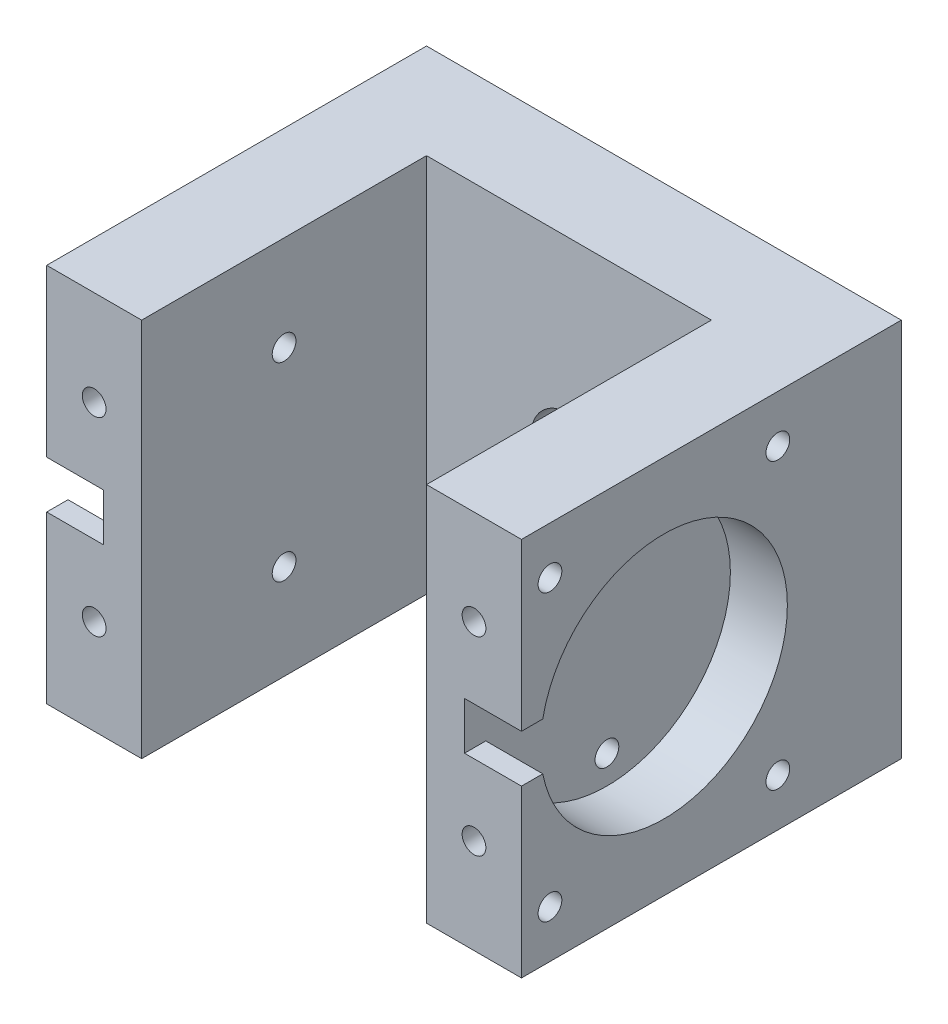
from build123d import *

# Parameters (mm, degrees)
SKETCH1_W                 = 50
SKETCH1_H                 = 40
BOSS_EXTRUDE1_DEPTH       = 40
CUT_EXTRUDE1_REACH        = 42
SKETCH2_W                 = 30
SKETCH2_H                 = 30
SKETCH3_R                 = 13
CUT_EXTRUDE2_DEPTH        = 6
SKETCH4_R                 = 13
CUT_EXTRUDE3_DEPTH        = 6
M3X0_5_TAPPED_HOLE1_D     = 2.5
M3X0_5_TAPPED_HOLE1_DEPTH = 6.5
M3X0_5_TAPPED_HOLE1_TIP   = 0.751075774
M3X0_5_TAPPED_HOLE2_D     = 2.5
M3X0_5_TAPPED_HOLE2_DEPTH = 6.5
M3X0_5_TAPPED_HOLE2_TIP   = 0.751075774
M3X0_5_TAPPED_HOLE3_D     = 2.5
M3X0_5_TAPPED_HOLE3_DEPTH = 4
M3X0_5_TAPPED_HOLE3_TIP   = 0.751075774
SKETCH13_R                = 4
CUT_EXTRUDE4_DEPTH        = 8
SKETCH15_W                = 4
SKETCH15_H                = 5
CUT_EXTRUDE5_DEPTH        = 6
SKETCH16_W                = 4
SKETCH16_H                = 5
CUT_EXTRUDE6_DEPTH        = 6
M3X0_5_TAPPED_HOLE4_D     = 2.5
M3X0_5_TAPPED_HOLE4_DEPTH = 6.5
M3X0_5_TAPPED_HOLE4_TIP   = 0.751075774
M3X0_5_TAPPED_HOLE5_D     = 2.5
M3X0_5_TAPPED_HOLE5_DEPTH = 6.5
M3X0_5_TAPPED_HOLE5_TIP   = 0.751075774


with BuildPart() as part:
    # Sketch1 → Boss-Extrude1 (new body)
    with BuildSketch(Plane(origin=(0, 0, 0), x_dir=(1, 0, 0), z_dir=(0, 1, 0))):
        Rectangle(SKETCH1_W, SKETCH1_H)
    extrude(amount=BOSS_EXTRUDE1_DEPTH)

    # Sketch2 → Cut-Extrude1 (cut, up to next)
    with BuildSketch(Plane(origin=(0, 40, 0), x_dir=(1, 0, 0), z_dir=(0, 1, 0)), mode=Mode.PRIVATE) as cut_extrude1_sk1:
        with Locations((0, -5)):
            Rectangle(SKETCH2_W, SKETCH2_H)
    cut_extrude1_tool1 = extrude(cut_extrude1_sk1.sketch, amount=-CUT_EXTRUDE1_REACH, mode=Mode.PRIVATE) & part.part
    add(cut_extrude1_tool1.solids().sort_by_distance((0, 40, 5))[0], mode=Mode.SUBTRACT)

    # Sketch3 → Cut-Extrude2 (cut)
    with BuildSketch(Plane.ZY.offset(25)):
        with Locations((5, 20)):
            Circle(SKETCH3_R)
    extrude(amount=-CUT_EXTRUDE2_DEPTH, mode=Mode.SUBTRACT)

    # Sketch4 → Cut-Extrude3 (cut)
    with BuildSketch(Plane(origin=(25, 0, 0), x_dir=(0, 0, -1), z_dir=(1, 0, 0))):
        with Locations((-5, 20)):
            Circle(SKETCH4_R)
    extrude(amount=-CUT_EXTRUDE3_DEPTH, mode=Mode.SUBTRACT)

    # M3x0.5 Tapped Hole1
    with Locations(Plane.ZY.offset(19)):
        with Locations((5, 30), (5, 10)):
            Hole(M3X0_5_TAPPED_HOLE1_D / 2, depth=M3X0_5_TAPPED_HOLE1_DEPTH)
            with Locations((0, 0, -(M3X0_5_TAPPED_HOLE1_DEPTH + M3X0_5_TAPPED_HOLE1_TIP / 2))):  # 118° drill point
                Cone(0, M3X0_5_TAPPED_HOLE1_D / 2, M3X0_5_TAPPED_HOLE1_TIP, mode=Mode.SUBTRACT)

    # M3x0.5 Tapped Hole2
    with Locations(Plane(origin=(19, 0, 0), x_dir=(0, 0, -1), z_dir=(1, 0, 0))):
        with Locations((-5, 30), (-5, 10)):
            Hole(M3X0_5_TAPPED_HOLE2_D / 2, depth=M3X0_5_TAPPED_HOLE2_DEPTH)
            with Locations((0, 0, -(M3X0_5_TAPPED_HOLE2_DEPTH + M3X0_5_TAPPED_HOLE2_TIP / 2))):  # 118° drill point
                Cone(0, M3X0_5_TAPPED_HOLE2_D / 2, M3X0_5_TAPPED_HOLE2_TIP, mode=Mode.SUBTRACT)

    # M3x0.5 Tapped Hole3
    with Locations(Plane.XY.offset(20)):
        with Locations((-20, 30), (-20, 10), (20, 10), (20, 30)):
            Hole(M3X0_5_TAPPED_HOLE3_D / 2, depth=M3X0_5_TAPPED_HOLE3_DEPTH)
            with Locations((0, 0, -(M3X0_5_TAPPED_HOLE3_DEPTH + M3X0_5_TAPPED_HOLE3_TIP / 2))):  # 118° drill point
                Cone(0, M3X0_5_TAPPED_HOLE3_D / 2, M3X0_5_TAPPED_HOLE3_TIP, mode=Mode.SUBTRACT)

    # Sketch13 → Cut-Extrude4 (cut)
    with BuildSketch(Plane.XY.offset(-10)):
        with Locations((0, 20)):
            Circle(SKETCH13_R)
    extrude(amount=-CUT_EXTRUDE4_DEPTH, mode=Mode.SUBTRACT)

    # Sketch15 → Cut-Extrude5 (cut)
    with BuildSketch(Plane(origin=(25, 0, 0), x_dir=(0, 0, -1), z_dir=(1, 0, 0))):
        with Locations((-18, 20)):
            Rectangle(SKETCH15_W, SKETCH15_H)
    extrude(amount=-CUT_EXTRUDE5_DEPTH, mode=Mode.SUBTRACT)

    # Sketch16 → Cut-Extrude6 (cut)
    with BuildSketch(Plane.ZY.offset(25)):
        with Locations((18, 20)):
            Rectangle(SKETCH16_W, SKETCH16_H)
    extrude(amount=-CUT_EXTRUDE6_DEPTH, mode=Mode.SUBTRACT)

    # M3x0.5 Tapped Hole4
    with Locations(Plane.ZY.offset(25)):
        with Locations((-7, 35), (-7, 5), (17, 5), (17, 35)):
            Hole(M3X0_5_TAPPED_HOLE4_D / 2, depth=M3X0_5_TAPPED_HOLE4_DEPTH)
            with Locations((0, 0, -(M3X0_5_TAPPED_HOLE4_DEPTH + M3X0_5_TAPPED_HOLE4_TIP / 2))):  # 118° drill point
                Cone(0, M3X0_5_TAPPED_HOLE4_D / 2, M3X0_5_TAPPED_HOLE4_TIP, mode=Mode.SUBTRACT)

    # M3x0.5 Tapped Hole5
    with Locations(Plane(origin=(25, 0, 0), x_dir=(0, 0, -1), z_dir=(1, 0, 0))):
        with Locations((-17, 35), (7, 35), (7, 5), (-17, 5)):
            Hole(M3X0_5_TAPPED_HOLE5_D / 2, depth=M3X0_5_TAPPED_HOLE5_DEPTH)
            with Locations((0, 0, -(M3X0_5_TAPPED_HOLE5_DEPTH + M3X0_5_TAPPED_HOLE5_TIP / 2))):  # 118° drill point
                Cone(0, M3X0_5_TAPPED_HOLE5_D / 2, M3X0_5_TAPPED_HOLE5_TIP, mode=Mode.SUBTRACT)


solid = part.part
